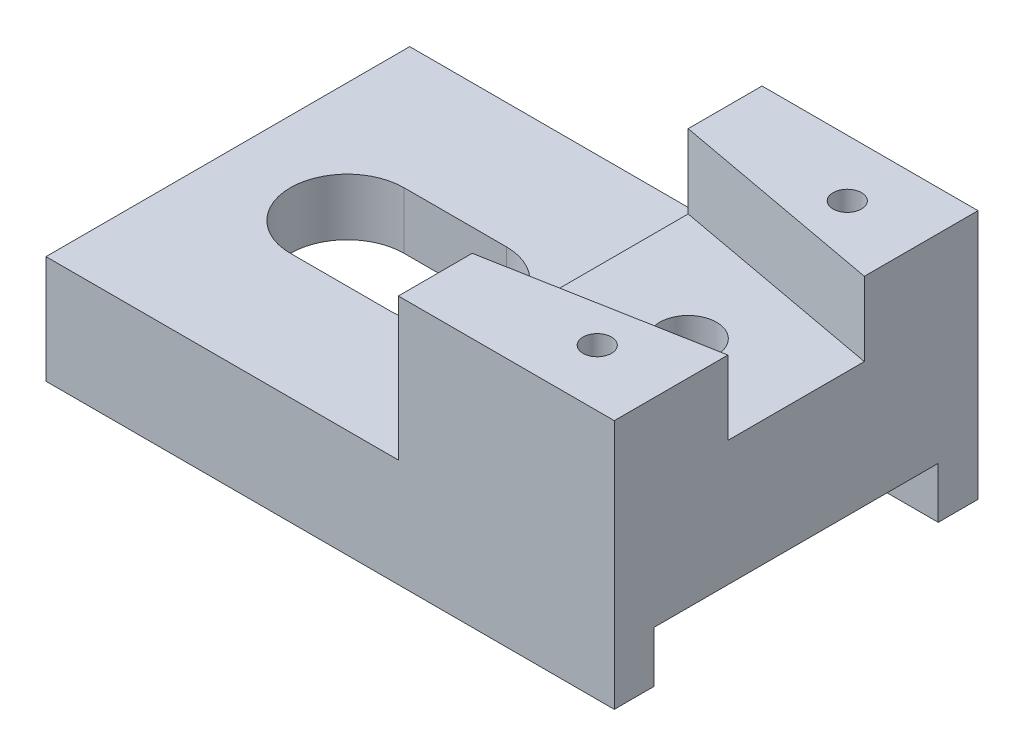
from build123d import *

# Parameters (mm, degrees)
SKETCH1_W                   = 100
SKETCH1_H                   = 19
SKETCH1_W_2                 = 38
SKETCH1_H_2                 = 25
BOSS_EXTRUDE1_DEPTH         = 64
CUT_EXTRUDE1_DEPTH          = 13
CUT_EXTRUDE2_DEPTH          = 20
CUT_EXTRUDE3_DEPTH          = 101
TAP_DRILL_FOR_M6_TAP1_D     = 5
TAP_DRILL_FOR_M6_TAP1_DEPTH = 20
TAP_DRILL_FOR_M6_TAP1_TIP   = 1.502151548
SKETCH9_R                   = 5
CUT_EXTRUDE4_DEPTH          = 32


with BuildPart() as part:
    # Sketch1 → Boss-Extrude1 (new body)
    with BuildSketch(Plane.XY):
        with Locations((5.391120507, -14.601479915)):
            Rectangle(SKETCH1_W, SKETCH1_H)
        with Locations((36.391120507, 7.398520085)):
            Rectangle(SKETCH1_W_2, SKETCH1_H_2)
    extrude(amount=-BOSS_EXTRUDE1_DEPTH)

    # Sketch2 → Cut-Extrude1 (cut)
    with BuildSketch(Plane(origin=(0, 19.898520085, 0), x_dir=(1, 0, 0), z_dir=(0, 1, 0))):
        Polygon((55.391120507, 44), (55.391120507, 20), (17.391120507, 13), (17.391120507, 51), align=None)
    extrude(amount=-CUT_EXTRUDE1_DEPTH, mode=Mode.SUBTRACT)

    # Sketch3 → Cut-Extrude2 (cut, through all)
    with BuildSketch(Plane(origin=(0, -5.101479915, 0), x_dir=(1, 0, 0), z_dir=(0, 1, 0))):
        with BuildLine():
            Line((-23.608879493, 42), (-5.608879493, 42))
            ThreePointArc((-5.608879493, 42), (4.391120507, 32), (-5.608879493, 22))
            Line((-5.608879493, 22), (-23.608879493, 22))
            ThreePointArc((-23.608879493, 22), (-33.608879493, 32), (-23.608879493, 42))
        make_face()
    extrude(amount=-CUT_EXTRUDE2_DEPTH, mode=Mode.SUBTRACT)

    # Sketch5 → Cut-Extrude3 (cut, through all)
    with BuildSketch(Plane.ZY.offset(44.608879493)):
        Polygon((-14.043777718, -15.101479915), (-7, -15.101479915), (-7, -24.101479915), (-57, -24.101479915), (-57, -15.101479915), (-52.287609929, -15.101479915), align=None)
    extrude(amount=-CUT_EXTRUDE3_DEPTH, mode=Mode.SUBTRACT)

    # Tap Drill for M6 Tap1
    with Locations(Plane(origin=(0, 19.898520085, 0), x_dir=(1, 0, 0), z_dir=(0, 1, 0))):
        with Locations((42.391120507, 54), (42.391120507, 10)):
            Hole(TAP_DRILL_FOR_M6_TAP1_D / 2, depth=TAP_DRILL_FOR_M6_TAP1_DEPTH)
            with Locations((0, 0, -(TAP_DRILL_FOR_M6_TAP1_DEPTH + TAP_DRILL_FOR_M6_TAP1_TIP / 2))):  # 118° drill point
                Cone(0, TAP_DRILL_FOR_M6_TAP1_D / 2, TAP_DRILL_FOR_M6_TAP1_TIP, mode=Mode.SUBTRACT)

    # Sketch9 → Cut-Extrude4 (cut, through all)
    with BuildSketch(Plane(origin=(0, 6.898520085, 0), x_dir=(1, 0, 0), z_dir=(0, 1, 0))):
        with Locations((36.391120507, 32)):
            Circle(SKETCH9_R)
    extrude(amount=-CUT_EXTRUDE4_DEPTH, mode=Mode.SUBTRACT)


solid = part.part
